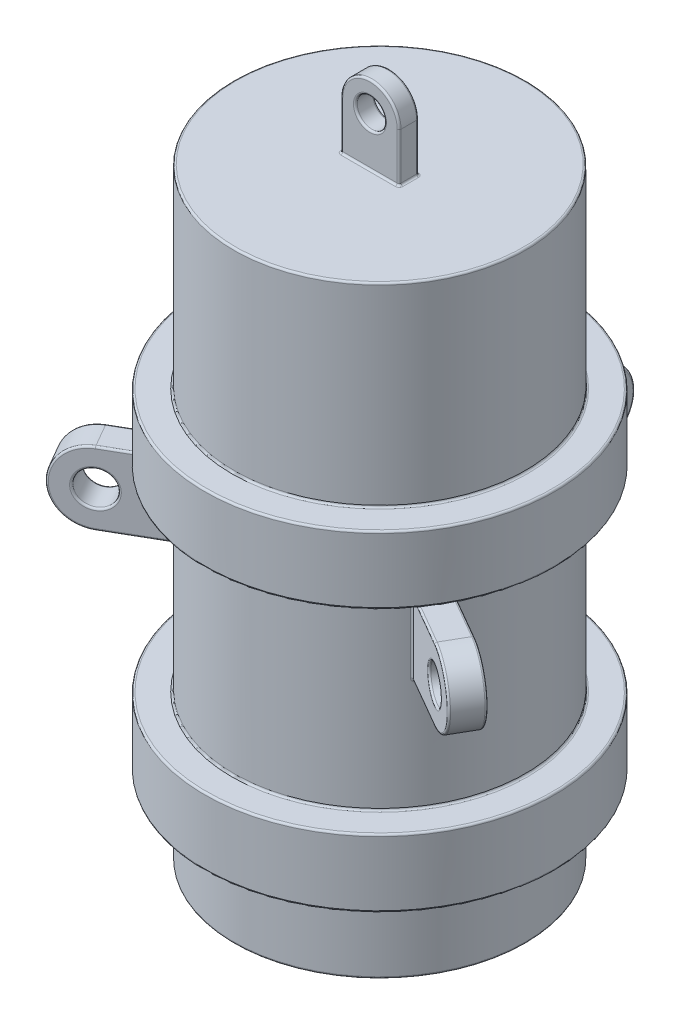
from build123d import *

# Parameters (mm, degrees)
SKETCH2_R           = 1.5
BOSS_EXTRUDE1_DEPTH = 1
SKETCH3_R           = 1.75
BOSS_EXTRUDE2_DEPTH = 1.5
CIRPATTERN1_COUNT   = 3
FILLET2_R           = 0.2


with BuildPart() as part:
    # Sketch1 → Revolve1 (revolve)
    with BuildSketch(Plane.XY):
        Polygon((-4, -29.085714286), (-15, -29.085714286), (-15, -21.085714286), (-18, -21.085714286), (-18, -14.085714286), (-15, -14.085714286), (-15, 5.914285714), (-18, 5.914285714), (-18, 12.914285714), (-15, 12.914285714), (-15, 32.914285714), (0, 32.914285714), (0, 31.914285714), (-14, 31.914285714), (-14, 11.914285714), (-17, 11.914285714), (-17, 6.914285714), (-14, 6.914285714), (-14, -15.085714286), (-17, -15.085714286), (-17, -20.085714286), (-14, -20.085714286), (-14, -28.085714286), (-4, -28.085714286), align=None)
    revolve(axis=Axis((0, 32.914285714, 0), (0, -1, 0)))

    # Sketch2 → Boss-Extrude1 (add, symmetric)
    with BuildSketch(Plane.XY):
        with BuildLine():
            Line((3, 37.914285714), (3, 32.914285714))
            Line((3, 32.914285714), (-3, 32.914285714))
            Line((-3, 32.914285714), (-3, 37.914285714))
            ThreePointArc((-3, 37.914285714), (0, 40.914285714), (3, 37.914285714))
        make_face()
        with Locations((0, 37.914285714)):
            Circle(SKETCH2_R, mode=Mode.SUBTRACT)
    extrude(amount=BOSS_EXTRUDE1_DEPTH, both=True)

    # Sketch3 → Boss-Extrude2 (add, symmetric)
    with BuildSketch(Plane(origin=(0, 0, 0), x_dir=(0, 0, -1), z_dir=(1, 0, 0))):
        with BuildLine():
            Line((14, 4.914285714), (21, 4.914285714))
            ThreePointArc((21, 4.914285714), (24.75, 1.164285714), (21, -2.585714286))
            Line((21, -2.585714286), (14, -2.585714286))
            Line((14, -2.585714286), (14, 4.914285714))
        make_face()
        with Locations((21, 1.164285714)):
            Circle(SKETCH3_R, mode=Mode.SUBTRACT)
    boss_extrude2 = extrude(amount=BOSS_EXTRUDE2_DEPTH, both=True)

    # CirPattern1: Boss-Extrude2 ×3 about axis
    cirpattern1_axis = Axis((0, 0, 0), (0, 1, 0))
    for i in range(1, CIRPATTERN1_COUNT):
        add(boss_extrude2.rotate(cirpattern1_axis, i * 360 / CIRPATTERN1_COUNT))

    # Fillet2
    fillet2_edges = [part.edges().sort_by_distance(p)[0] for p in [
        (13.675265955, 1.164285714, 6.163367673),
        (12.175265955, 1.164285714, 8.761443884),
        (16.305899717, -2.585714286, 7.682164783),
        (16.305899717, 4.914285714, 7.682164783),
        (14.805899717, -2.585714286, 10.280240995),
        (20.684128744, 1.164285714, 13.674038106),
        (14.805899717, 4.914285714, 10.280240995),
        (17.420989023, 1.164285714, 8.325961894),
        (12.990381057, -2.585714286, 7.5),
        (22.184128744, 1.164285714, 11.075961894),
        (12.990381057, 4.914285714, 7.5),
        (15.920989023, 1.164285714, 10.924038106),
        (14, 31.914285714, 0),
        (14, 11.914285714, 0),
        (17, 11.914285714, 0),
        (17, 6.914285714, 0),
        (14, 6.914285714, 0),
        (14, -15.085714286, 0),
        (17, -15.085714286, 0),
        (17, -20.085714286, 0),
        (14, -20.085714286, 0),
        (14, -28.085714286, 0),
        (4, -28.085714286, 0),
        (4, -29.085714286, 0),
        (15, -29.085714286, 0),
        (15, -21.085714286, 0),
        (18, -21.085714286, 0),
        (18, -14.085714286, 0),
        (15, -14.085714286, 0),
        (15, 5.914285714, 0),
        (18, 5.914285714, 0),
        (18, 12.914285714, 0),
        (15, 12.914285714, 0),
        (15, 32.914285714, 0),
        (0, 40.914285714, 1),
        (-3, 35.414285714, 1),
        (0, 32.914285714, 1),
        (3, 35.414285714, 1),
        (-1.5, 37.914285714, -1),
        (0, 40.914285714, -1),
        (-3, 35.414285714, -1),
        (0, 32.914285714, -1),
        (-3, 32.914285714, 0),
        (3, 35.414285714, -1),
        (3, 32.914285714, 0),
        (-1.5, 37.914285714, 1),
        (-1.5, 1.164285714, -14.924811557),
        (1.5, 1.164285714, -14.924811557),
        (-1.5, -2.585714286, -17.962405778),
        (-1.5, 4.914285714, -17.962405778),
        (1.5, -2.585714286, -17.962405778),
        (1.5, 1.164285714, -24.75),
        (1.5, 4.914285714, -17.962405778),
        (-1.5, 1.164285714, -19.25),
        (0, -2.585714286, -15),
        (-1.5, 1.164285714, -24.75),
        (0, 4.914285714, -15),
        (1.5, 1.164285714, -19.25),
        (-12.175265955, 1.164285714, 8.761443884),
        (-13.675265955, 1.164285714, 6.163367673),
        (-14.805899717, -2.585714286, 10.280240995),
        (-14.805899717, 4.914285714, 10.280240995),
        (-16.305899717, -2.585714286, 7.682164783),
        (-22.184128744, 1.164285714, 11.075961894),
        (-16.305899717, 4.914285714, 7.682164783),
        (-15.920989023, 1.164285714, 10.924038106),
        (-12.990381057, -2.585714286, 7.5),
        (-20.684128744, 1.164285714, 13.674038106),
        (-12.990381057, 4.914285714, 7.5),
        (-17.420989023, 1.164285714, 8.325961894),
    ]]
    fillet(fillet2_edges, radius=FILLET2_R)


solid = part.part
